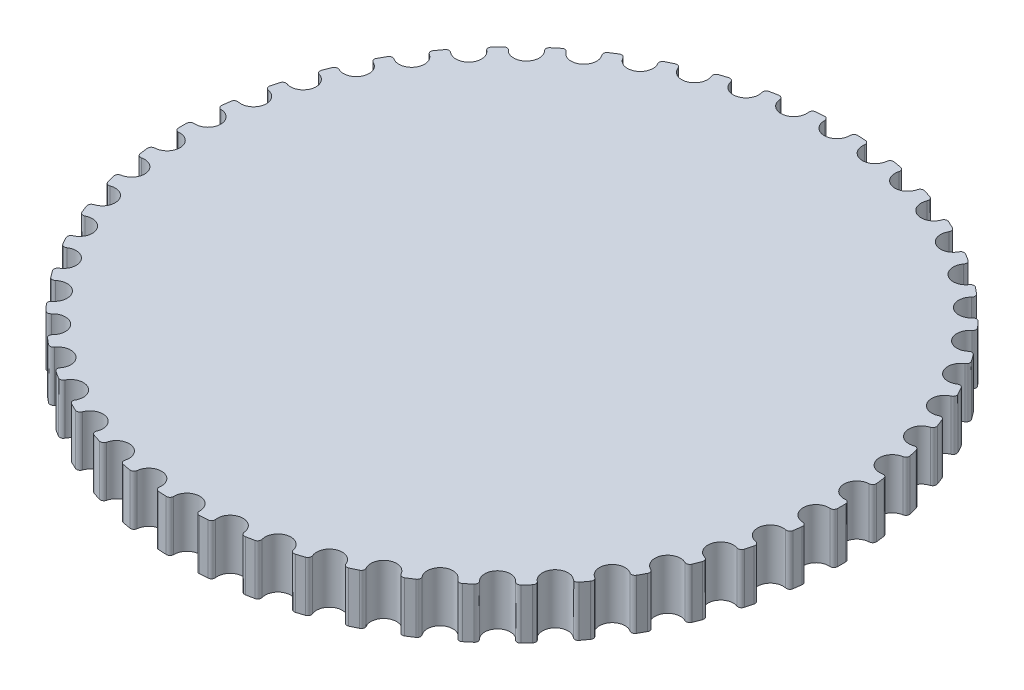
from build123d import *

# Parameters (mm, degrees)
BOSS_EXTRUDE1_DEPTH = 3
CIRPATTERN1_COUNT   = 50


with BuildPart() as part:
    # Sketch1 → Boss-Extrude1 (new, symmetric)
    with BuildSketch(Plane(origin=(0, 0, 0), x_dir=(1, 0, 0), z_dir=(0, 1, 0))):
        with BuildLine():
            ThreePointArc((0, 37.157498456), (1.093602334, 37.619644311), (1.52438003, 38.725978543))
            ThreePointArc((1.52438003, 38.725978543), (1.653495048, 39.045603702), (1.975869525, 39.167692303))
            ThreePointArc((1.975869525, 39.167692303), (2.462487099, 39.140111625), (2.948724324, 39.106485467))
            ThreePointArc((2.948724324, 39.106485467), (3.253255023, 38.944955335), (3.341292276, 38.611668114))
            ThreePointArc((3.341292276, 38.611668114), (3.630012714, 37.460066896), (4.657069433, 36.864500482))
            ThreePointArc((4.657069433, 36.864500482), (-2.333138632, -37.084176621), (0, 37.157498456))
        make_face()
    boss_extrude1 = extrude(amount=BOSS_EXTRUDE1_DEPTH, both=True)

    # CirPattern1: Boss-Extrude1 ×50 about axis
    cirpattern1_axis = Axis((0, 3.3, 0), (0, -1, 0))
    for i in range(1, CIRPATTERN1_COUNT):
        add(boss_extrude1.rotate(cirpattern1_axis, i * 360 / CIRPATTERN1_COUNT))


solid = part.part
